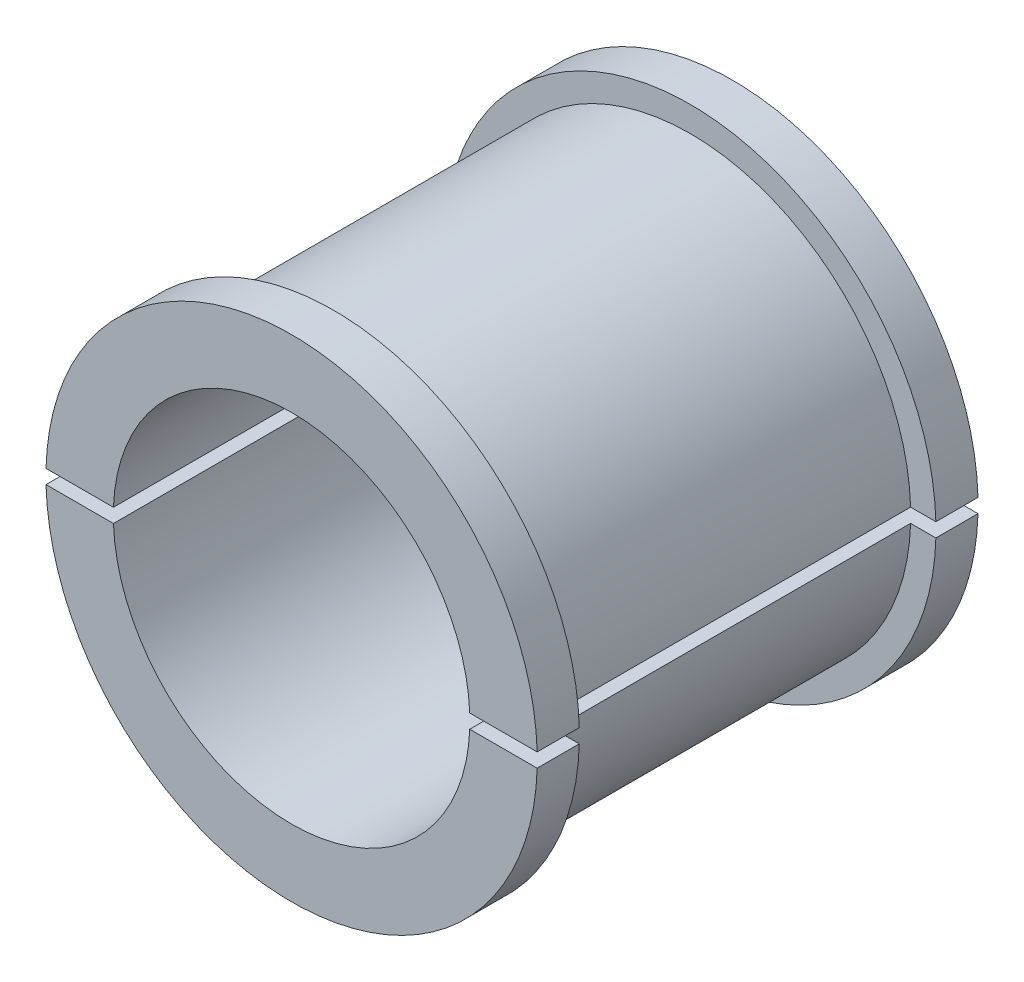
from build123d import *

# Parameters (mm, degrees)
SKETCH2_W               = 42.06954519
SKETCH2_H               = 1
CUT_EXTRUDE1_DEPTH      = 16.7
CUT_EXTRUDE1_DEPTH_BACK = 16.7


with BuildPart() as part:
    # Sketch1 → Revolve1 (revolve)
    with BuildSketch(Plane(origin=(0, 0, 0), x_dir=(0, 0, -1), z_dir=(1, 0, 0))):
        Polygon((-15.7, 12.7), (-15.7, 17.5), (-12.7, 17.5), (-12.7, 15.7), (12.7, 15.7), (12.7, 17.5), (15.7, 17.5), (15.7, 12.7), align=None)
    revolve(axis=Axis((0, 0, 67.856305953), (0, 0, -1)))

    # Sketch2 → Cut-Extrude1 (cut, two sides)
    with BuildSketch(Plane.XY) as cut_extrude1_sk:
        Rectangle(SKETCH2_W, SKETCH2_H)
    extrude(amount=CUT_EXTRUDE1_DEPTH, mode=Mode.SUBTRACT)
    extrude(cut_extrude1_sk.sketch, amount=-CUT_EXTRUDE1_DEPTH_BACK, mode=Mode.SUBTRACT)


solid = part.part
